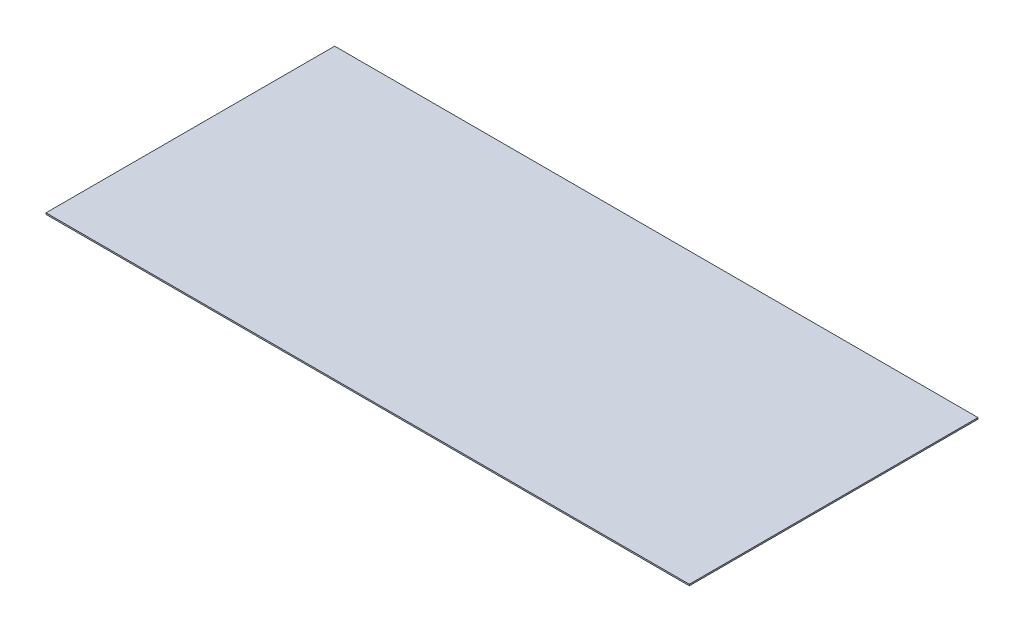
from build123d import *

# Parameters (mm, degrees)
BOSS_EXTRUDE1_DEPTH = 1.5875


with BuildPart() as part:
    # Sketch1 → Boss-Extrude1 (new body)
    with BuildSketch(Plane(origin=(0, 0, 0), x_dir=(1, 0, 0), z_dir=(0, 1, 0))):
        Polygon((368.052052176, -7.709877142), (513.594052176, -7.709877142), (724.922052176, -7.709877142), (724.922052176, 314.362122858), (7.118052176, 314.362122858), (7.118052176, -7.709877142), align=None)
    extrude(amount=BOSS_EXTRUDE1_DEPTH)


solid = part.part
